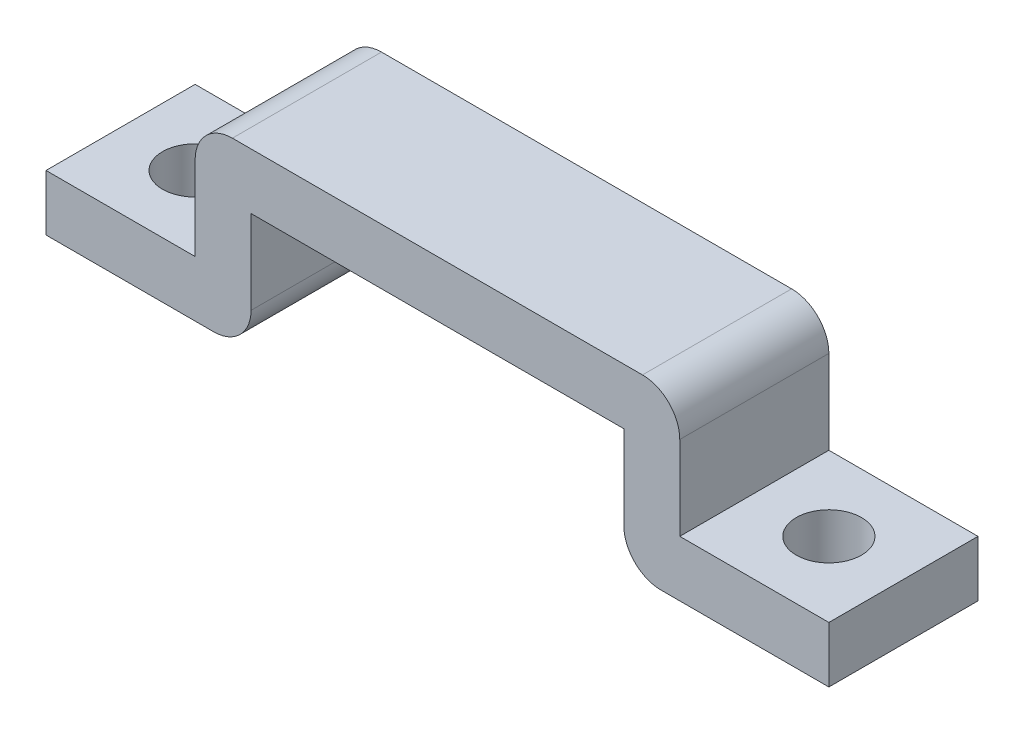
from build123d import *

# Parameters (mm, degrees)
BOSS_EXTRUDE1_DEPTH = 8
SKETCH2_R           = 1.75
CUT_EXTRUDE1_DEPTH  = 4


with BuildPart() as part:
    # Sketch1 → Boss-Extrude1 (new body)
    with BuildSketch(Plane.XY):
        with BuildLine():
            Line((-21, 0), (-12, 0))
            ThreePointArc((-12, 0), (-10.585786438, 0.585786438), (-10, 2))
            Line((-10, 2), (-10, 6.5))
            Line((-10, 6.5), (10, 6.5))
            Line((10, 6.5), (10, 2))
            ThreePointArc((10, 2), (10.585786438, 0.585786438), (12, 0))
            Line((12, 0), (21, 0))
            Line((21, 0), (21, 3))
            Line((21, 3), (13, 3))
            Line((13, 3), (13, 7.5))
            ThreePointArc((13, 7.5), (12.414213562, 8.914213562), (11, 9.5))
            Line((11, 9.5), (-11, 9.5))
            ThreePointArc((-11, 9.5), (-12.414213562, 8.914213562), (-13, 7.5))
            Line((-13, 7.5), (-13, 3))
            Line((-13, 3), (-21, 3))
            Line((-21, 3), (-21, 0))
        make_face()
    extrude(amount=BOSS_EXTRUDE1_DEPTH)

    # Sketch2 → Cut-Extrude1 (cut, through all)
    with BuildSketch(Plane(origin=(0, 3, 0), x_dir=(1, 0, 0), z_dir=(0, 1, 0))):
        with Locations((-17, -4)):
            Circle(SKETCH2_R)
        with Locations((17, -4)):
            Circle(SKETCH2_R)
    extrude(amount=-CUT_EXTRUDE1_DEPTH, mode=Mode.SUBTRACT)


solid = part.part
